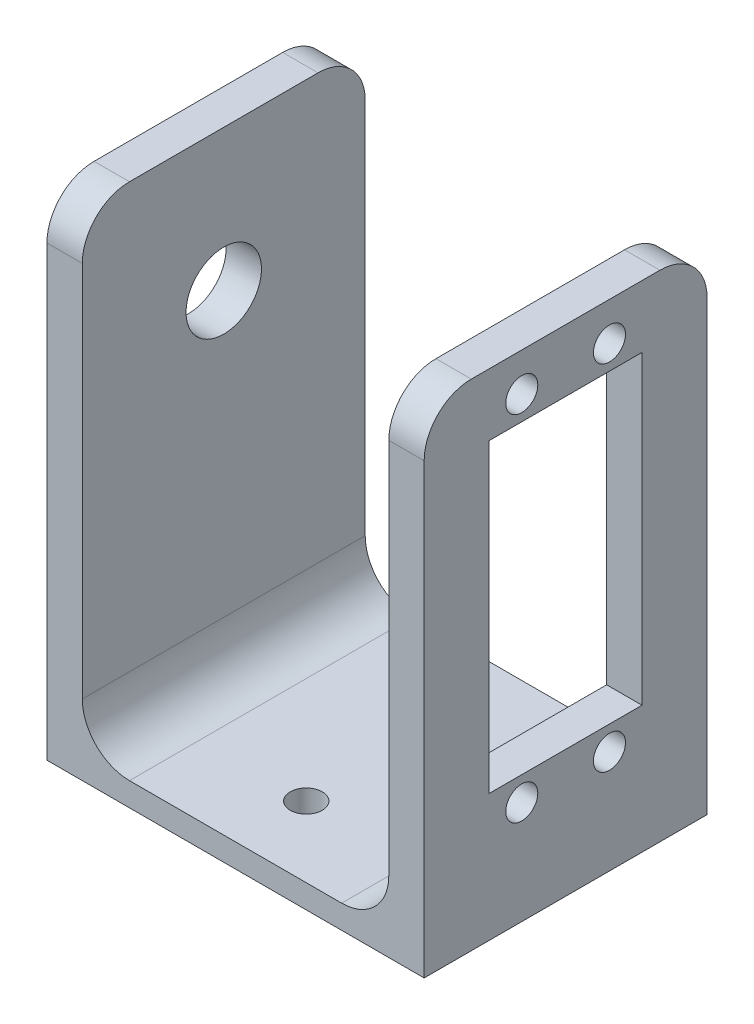
from build123d import *

# Parameters (mm, degrees)
SKETCH1_W           = 50.8
SKETCH1_H           = 38.1
BOSS_EXTRUDE1_DEPTH = 3.175
SKETCH2_W           = 4.7625
SKETCH2_H           = 38.1
BOSS_EXTRUDE2_DEPTH = 63.5
FILLET1_R           = 6.35
CUT_EXTRUDE1_REACH  = 52.8
SKETCH3_R           = 2.159
SKETCH3_W           = 20.574
SKETCH3_H           = 41.148
CUT_EXTRUDE2_REACH  = 5.175
SKETCH4_R           = 2.159
CUT_EXTRUDE3_REACH  = 52.8
SKETCH5_R           = 5.08


with BuildPart() as part:
    # Sketch1 → Boss-Extrude1 (new body)
    with BuildSketch(Plane(origin=(0, 0, 0), x_dir=(1, 0, 0), z_dir=(0, 1, 0))):
        with Locations((25.4, 19.05)):
            Rectangle(SKETCH1_W, SKETCH1_H)
    extrude(amount=BOSS_EXTRUDE1_DEPTH)

    # Sketch2 → Boss-Extrude2 (add)
    with BuildSketch(Plane(origin=(0, 3.175, 0), x_dir=(1, 0, 0), z_dir=(0, 1, 0))):
        with Locations((48.41875, 19.05)):
            Rectangle(SKETCH2_W, SKETCH2_H)
        with Locations((2.38125, 19.05)):
            Rectangle(SKETCH2_W, SKETCH2_H)
    extrude(amount=BOSS_EXTRUDE2_DEPTH)

    # Fillet1
    fillet1_edges = [part.edges().sort_by_distance(p)[0] for p in [
        (46.0375, 3.175, -19.05),
        (48.41875, 66.675, -38.1),
        (48.41875, 66.675, 0),
        (4.7625, 3.175, -19.05),
        (2.38125, 66.675, -38.1),
        (2.38125, 66.675, 0),
    ]]
    fillet(fillet1_edges, radius=FILLET1_R)

    # Sketch3 → Cut-Extrude1 (cut, up to next)
    with BuildSketch(Plane(origin=(50.8, 0, 0), x_dir=(0, 0, -1), z_dir=(1, 0, 0)), mode=Mode.PRIVATE) as cut_extrude1_sk1:
        with Locations((24.9555, 61.5315)):
            Circle(SKETCH3_R)
    cut_extrude1_tool1 = extrude(cut_extrude1_sk1.sketch, amount=-CUT_EXTRUDE1_REACH, mode=Mode.PRIVATE) & part.part
    add(cut_extrude1_tool1.solids().sort_by_distance((50.8, 61.5315, -24.9555))[0], mode=Mode.SUBTRACT)
    # Sketch3 → Cut-Extrude1 (cut, up to next)
    with BuildSketch(Plane(origin=(50.8, 0, 0), x_dir=(0, 0, -1), z_dir=(1, 0, 0)), mode=Mode.PRIVATE) as cut_extrude1_sk2:
        with Locations((13.1445, 61.5315)):
            Circle(SKETCH3_R)
    cut_extrude1_tool2 = extrude(cut_extrude1_sk2.sketch, amount=-CUT_EXTRUDE1_REACH, mode=Mode.PRIVATE) & part.part
    add(cut_extrude1_tool2.solids().sort_by_distance((50.8, 61.5315, -13.1445))[0], mode=Mode.SUBTRACT)
    # Sketch3 → Cut-Extrude1 (cut, up to next)
    with BuildSketch(Plane(origin=(50.8, 0, 0), x_dir=(0, 0, -1), z_dir=(1, 0, 0)), mode=Mode.PRIVATE) as cut_extrude1_sk3:
        with Locations((13.1445, 13.9065)):
            Circle(SKETCH3_R)
    cut_extrude1_tool3 = extrude(cut_extrude1_sk3.sketch, amount=-CUT_EXTRUDE1_REACH, mode=Mode.PRIVATE) & part.part
    add(cut_extrude1_tool3.solids().sort_by_distance((50.8, 13.9065, -13.1445))[0], mode=Mode.SUBTRACT)
    # Sketch3 → Cut-Extrude1 (cut, up to next)
    with BuildSketch(Plane(origin=(50.8, 0, 0), x_dir=(0, 0, -1), z_dir=(1, 0, 0)), mode=Mode.PRIVATE) as cut_extrude1_sk4:
        with Locations((24.9555, 13.9065)):
            Circle(SKETCH3_R)
    cut_extrude1_tool4 = extrude(cut_extrude1_sk4.sketch, amount=-CUT_EXTRUDE1_REACH, mode=Mode.PRIVATE) & part.part
    add(cut_extrude1_tool4.solids().sort_by_distance((50.8, 13.9065, -24.9555))[0], mode=Mode.SUBTRACT)
    # Sketch3 → Cut-Extrude1 (cut, up to next)
    with BuildSketch(Plane(origin=(50.8, 0, 0), x_dir=(0, 0, -1), z_dir=(1, 0, 0)), mode=Mode.PRIVATE) as cut_extrude1_sk5:
        with Locations((19.05, 37.719)):
            Rectangle(SKETCH3_W, SKETCH3_H)
    cut_extrude1_tool5 = extrude(cut_extrude1_sk5.sketch, amount=-CUT_EXTRUDE1_REACH, mode=Mode.PRIVATE) & part.part
    add(cut_extrude1_tool5.solids().sort_by_distance((50.8, 37.719, -19.05))[0], mode=Mode.SUBTRACT)

    # Sketch4 → Cut-Extrude2 (cut, up to next)
    with BuildSketch(Plane(origin=(0, 3.175, 0), x_dir=(1, 0, 0), z_dir=(0, 1, 0)), mode=Mode.PRIVATE) as cut_extrude2_sk1:
        with Locations((25.4, 28.575)):
            Circle(SKETCH4_R)
    cut_extrude2_tool1 = extrude(cut_extrude2_sk1.sketch, amount=-CUT_EXTRUDE2_REACH, mode=Mode.PRIVATE) & part.part
    add(cut_extrude2_tool1.solids().sort_by_distance((25.4, 3.175, -28.575))[0], mode=Mode.SUBTRACT)
    # Sketch4 → Cut-Extrude2 (cut, up to next)
    with BuildSketch(Plane(origin=(0, 3.175, 0), x_dir=(1, 0, 0), z_dir=(0, 1, 0)), mode=Mode.PRIVATE) as cut_extrude2_sk2:
        with Locations((25.4, 9.525)):
            Circle(SKETCH4_R)
    cut_extrude2_tool2 = extrude(cut_extrude2_sk2.sketch, amount=-CUT_EXTRUDE2_REACH, mode=Mode.PRIVATE) & part.part
    add(cut_extrude2_tool2.solids().sort_by_distance((25.4, 3.175, -9.525))[0], mode=Mode.SUBTRACT)

    # Sketch5 → Cut-Extrude3 (cut, up to next)
    with BuildSketch(Plane.ZY, mode=Mode.PRIVATE) as cut_extrude3_sk1:
        with Locations((-19.05, 47.625)):
            Circle(SKETCH5_R)
    cut_extrude3_tool1 = extrude(cut_extrude3_sk1.sketch, amount=-CUT_EXTRUDE3_REACH, mode=Mode.PRIVATE) & part.part
    add(cut_extrude3_tool1.solids().sort_by_distance((0, 47.625, -19.05))[0], mode=Mode.SUBTRACT)


solid = part.part
